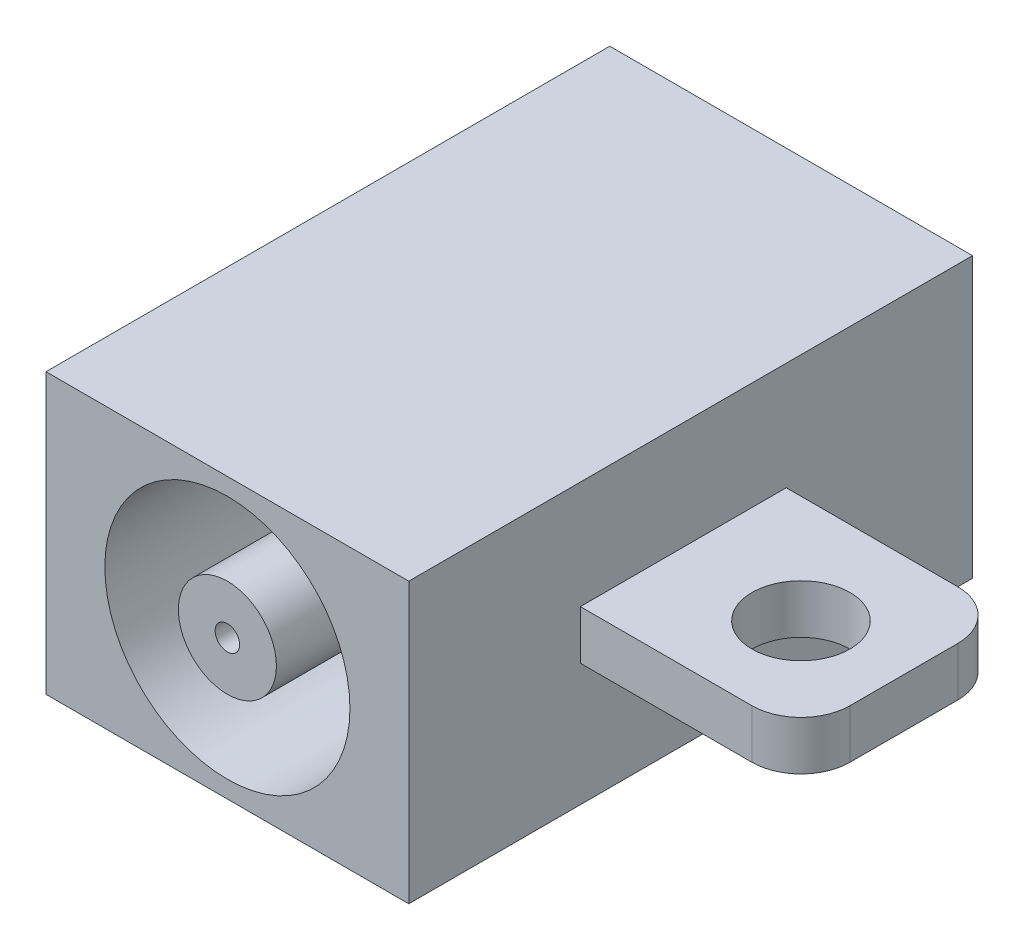
from build123d import *

# Parameters (mm, degrees)
SKETCH1_W           = 7.4
SKETCH1_H           = 11.5
BOSS_EXTRUDE1_DEPTH = 5.7
SKETCH2_R           = 2.5
CUT_EXTRUDE1_DEPTH  = 5.5
SKETCH3_R           = 1
BOSS_EXTRUDE2_DEPTH = 5.5
SKETCH4_R           = 0.25
CUT_EXTRUDE2_DEPTH  = 5.5
SKETCH5_W           = 4.2
SKETCH5_H           = 1
BOSS_EXTRUDE3_DEPTH = 4.5
FILLET1_R           = 1
CUT_EXTRUDE3_REACH  = 5.5
SKETCH6_R           = 1


with BuildPart() as part:
    # Sketch1 → Boss-Extrude1 (new body)
    with BuildSketch(Plane(origin=(0, 0, 0), x_dir=(1, 0, 0), z_dir=(0, 1, 0))):
        with Locations((3.7, 5.75)):
            Rectangle(SKETCH1_W, SKETCH1_H)
    extrude(amount=BOSS_EXTRUDE1_DEPTH)

    # Sketch2 → Cut-Extrude1 (cut)
    with BuildSketch(Plane.XY):
        with Locations((3.7, 2.85)):
            Circle(SKETCH2_R)
    extrude(amount=-CUT_EXTRUDE1_DEPTH, mode=Mode.SUBTRACT)

    # Sketch3 → Boss-Extrude2 (add)
    with BuildSketch(Plane.XY):
        with Locations((3.7, 2.85)):
            Circle(SKETCH3_R)
    extrude(amount=-BOSS_EXTRUDE2_DEPTH)

    # Sketch4 → Cut-Extrude2 (cut)
    with BuildSketch(Plane.XY):
        with Locations((3.7, 2.85)):
            Circle(SKETCH4_R)
    extrude(amount=-CUT_EXTRUDE2_DEPTH, mode=Mode.SUBTRACT)

    # Sketch5 → Boss-Extrude3 (add)
    with BuildSketch(Plane(origin=(7.4, 0, 0), x_dir=(0, 0, -1), z_dir=(1, 0, 0))):
        with Locations((5.6, 3)):
            Rectangle(SKETCH5_W, SKETCH5_H)
    extrude(amount=BOSS_EXTRUDE3_DEPTH)

    # Fillet1
    fillet1_edges = [part.edges().sort_by_distance(p)[0] for p in [
        (11.9, 3, -3.5),
        (11.9, 3, -7.7),
    ]]
    fillet(fillet1_edges, radius=FILLET1_R)

    # Sketch6 → Cut-Extrude3 (cut, up to next)
    with BuildSketch(Plane(origin=(0, 3.5, 0), x_dir=(1, 0, 0), z_dir=(0, 1, 0)), mode=Mode.PRIVATE) as cut_extrude3_sk1:
        with Locations((9.9, 5.5)):
            Circle(SKETCH6_R)
    cut_extrude3_tool1 = extrude(cut_extrude3_sk1.sketch, amount=-CUT_EXTRUDE3_REACH, mode=Mode.PRIVATE) & part.part
    add(cut_extrude3_tool1.solids().sort_by_distance((9.9, 3.5, -5.5))[0], mode=Mode.SUBTRACT)


solid = part.part
